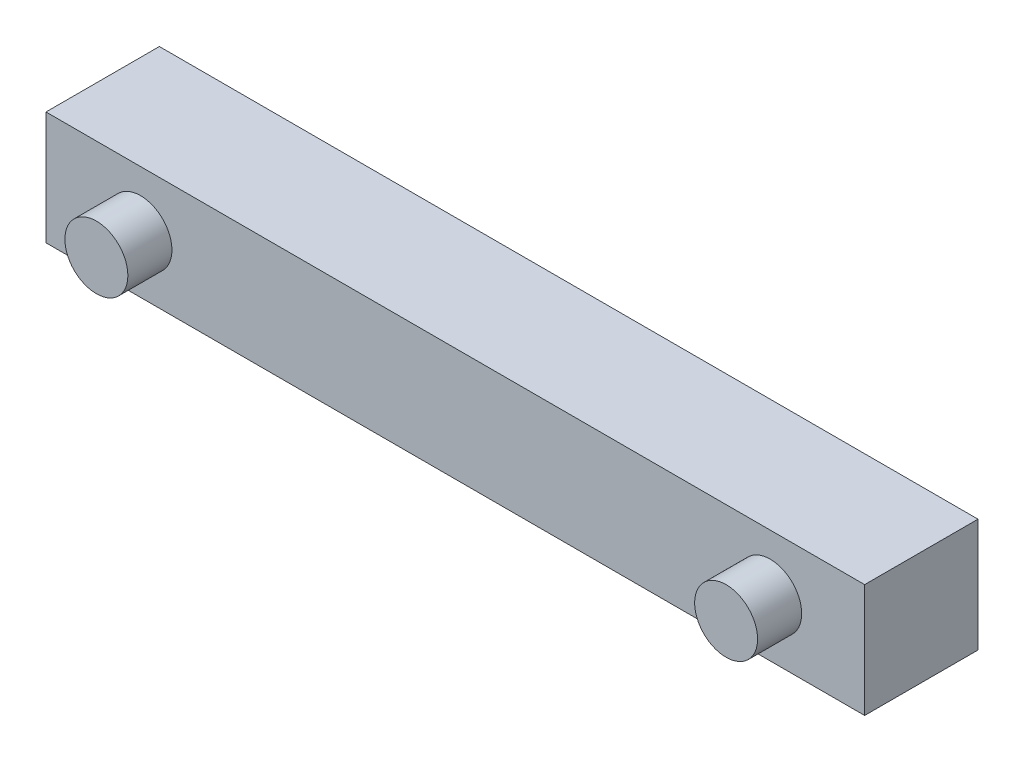
from build123d import *

# Parameters (mm, degrees)
SKETCH1_W           = 1651
SKETCH1_H           = 228.6
BOSS_EXTRUDE1_DEPTH = 228.6
SKETCH2_R           = 63.5
BOSS_EXTRUDE2_DEPTH = 88.9


with BuildPart() as part:
    # Sketch1 → Boss-Extrude1 (new body)
    with BuildSketch(Plane.XY):
        with Locations((825.5, 114.3)):
            Rectangle(SKETCH1_W, SKETCH1_H)
    extrude(amount=BOSS_EXTRUDE1_DEPTH)

    # Sketch2 → Boss-Extrude2 (add)
    with BuildSketch(Plane.XY.offset(228.6)):
        with Locations((190.5, 114.3)):
            Circle(SKETCH2_R)
        with Locations(Location((1460.5, 114.3, 0), (0, 0, 180))):  # turned: the seam where the file's is
            Circle(SKETCH2_R)
    extrude(amount=BOSS_EXTRUDE2_DEPTH)


solid = part.part
